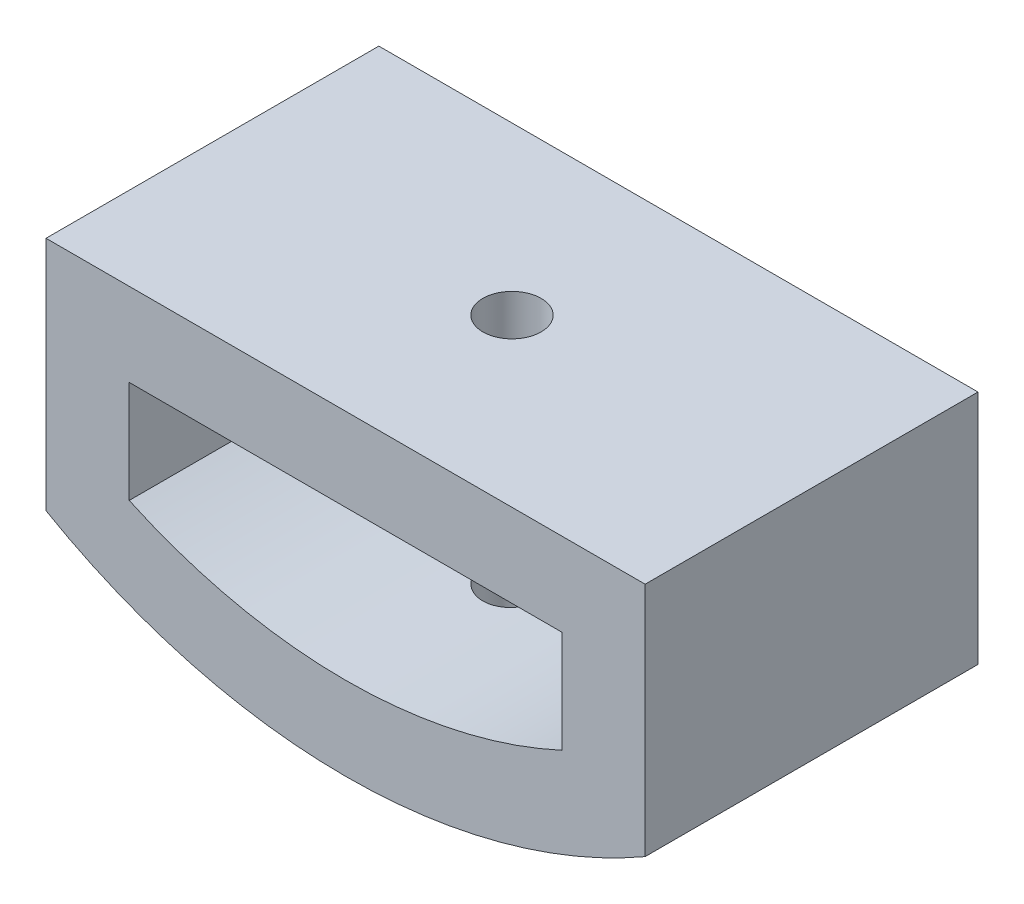
from build123d import *

# Parameters (mm, degrees)
BOSS_EXTRUDE1_DEPTH = 10
SKETCH2_R           = 0.875
CUT_EXTRUDE3_DEPTH  = 23


with BuildPart() as part:
    # Sketch1 → Boss-Extrude1 (new body)
    with BuildSketch(Plane.XY):
        with BuildLine():
            ThreePointArc((6.5, -14.071247279), (3.327586751, -15.138598562), (0, -15.5))
            ThreePointArc((0, -15.5), (-3.327586751, -15.138598562), (-6.5, -14.071247279))
            ThreePointArc((-6.5, -14.071247279), (-7.783922131, -13.403751574), (-9, -12.619429464))
            Line((-9, -12.619429464), (-9, -15.588457268))
            ThreePointArc((-9, -15.588457268), (0, -18), (9, -15.588457268))
            Line((9, -15.588457268), (9, -12.619429464))
            ThreePointArc((9, -12.619429464), (7.783922131, -13.403751574), (6.5, -14.071247279))
        make_face()
        with BuildLine():
            Line((-6.5, -11), (0, -11))
            Line((0, -11), (0, -8.5))
            Line((0, -8.5), (-9, -8.5))
            Line((-9, -8.5), (-9, -12.619429464))
            ThreePointArc((-9, -12.619429464), (-7.783922131, -13.403751574), (-6.5, -14.071247279))
            Line((-6.5, -14.071247279), (-6.5, -12.619429464))
            Line((-6.5, -12.619429464), (-6.5, -11))
        make_face()
        with BuildLine():
            Line((0, -8.5), (0, -11))
            Line((0, -11), (6.5, -11))
            Line((6.5, -11), (6.5, -12.619429464))
            Line((6.5, -12.619429464), (6.5, -14.071247279))
            ThreePointArc((6.5, -14.071247279), (7.783922131, -13.403751574), (9, -12.619429464))
            Line((9, -12.619429464), (9, -8.5))
            Line((9, -8.5), (0, -8.5))
        make_face()
    extrude(amount=BOSS_EXTRUDE1_DEPTH)

    # Sketch2 → Cut-Extrude3 (cut)
    with BuildSketch(Plane(origin=(0, 0, 0), x_dir=(1, 0, 0), z_dir=(0, 1, 0))):
        with Locations((0, -5)):
            Circle(SKETCH2_R)
    extrude(amount=-CUT_EXTRUDE3_DEPTH, mode=Mode.SUBTRACT)


solid = part.part
